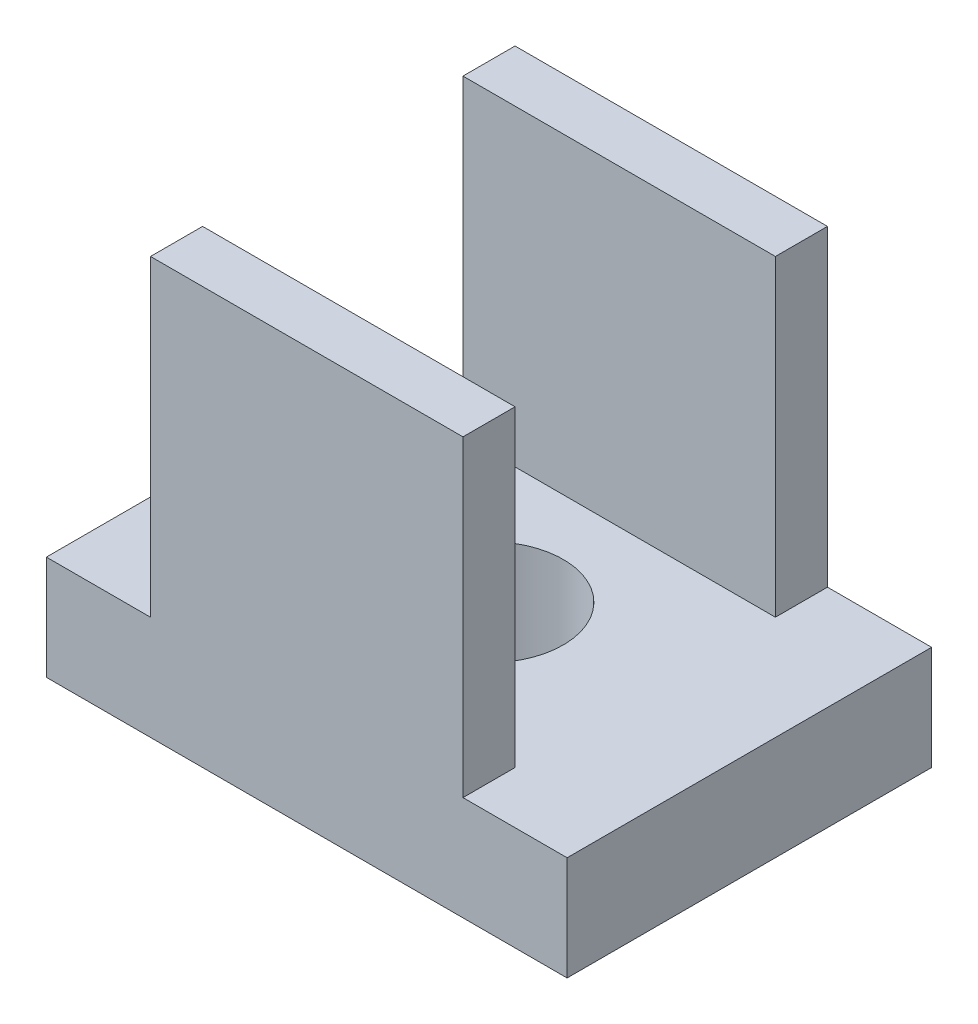
from build123d import *

# Parameters (mm, degrees)
SKETCH1_W           = 10
SKETCH1_H           = 7
BOSS_EXTRUDE1_DEPTH = 2
SKETCH2_R           = 1.425
CUT_EXTRUDE1_DEPTH  = 2
SKETCH3_W           = 6
SKETCH3_H           = 1
BOSS_EXTRUDE2_DEPTH = 6


with BuildPart() as part:
    # Sketch1 → Boss-Extrude1 (new body)
    with BuildSketch(Plane(origin=(0, 0, 0), x_dir=(1, 0, 0), z_dir=(0, 1, 0))):
        Rectangle(SKETCH1_W, SKETCH1_H)
    extrude(amount=BOSS_EXTRUDE1_DEPTH)

    # Sketch2 → Cut-Extrude1 (cut)
    with BuildSketch(Plane(origin=(0, 2, 0), x_dir=(1, 0, 0), z_dir=(0, 1, 0))):
        Circle(SKETCH2_R)
    extrude(amount=-CUT_EXTRUDE1_DEPTH, mode=Mode.SUBTRACT)

    # Sketch3 → Boss-Extrude2 (add)
    with BuildSketch(Plane(origin=(0, 2, 0), x_dir=(1, 0, 0), z_dir=(0, 1, 0))):
        with Locations((0, 3)):
            Rectangle(SKETCH3_W, SKETCH3_H)
        with Locations((0, -3)):
            Rectangle(SKETCH3_W, SKETCH3_H)
    extrude(amount=BOSS_EXTRUDE2_DEPTH)


solid = part.part
